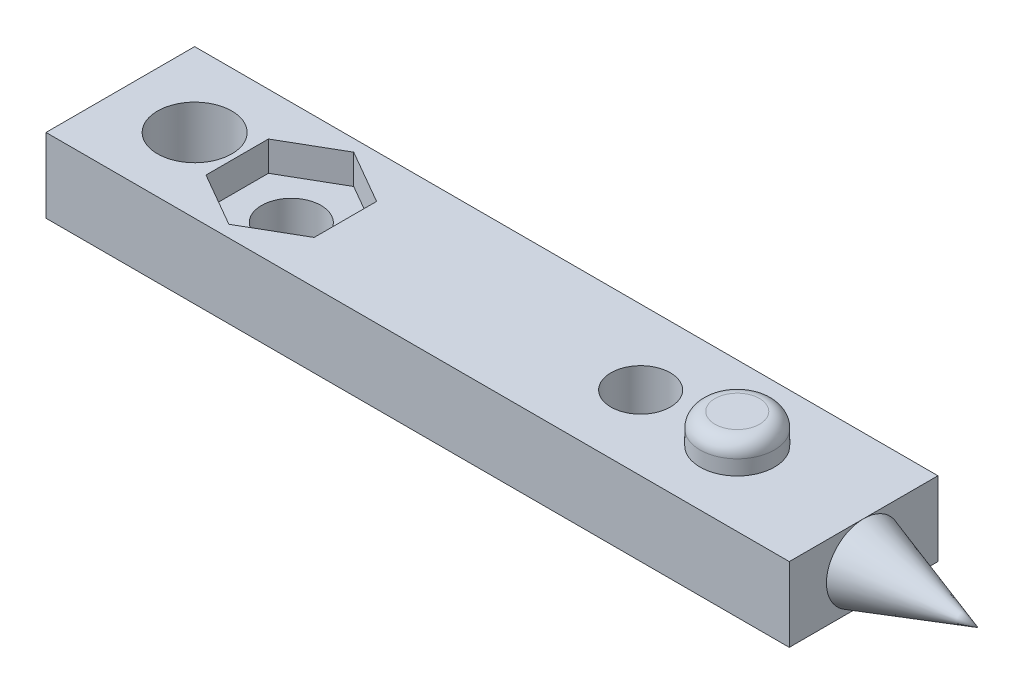
from build123d import *

# Parameters (mm, degrees)
SKETCH1_W           = 50
SKETCH1_H           = 10
BOSS_EXTRUDE1_DEPTH = 5
SKETCH2_R           = 2.5
SKETCH2_R_2         = 2
CUT_EXTRUDE1_DEPTH  = 5
SKETCH3_R           = 2
CUT_EXTRUDE2_DEPTH  = 5
CUT_EXTRUDE3_DEPTH  = 2
SKETCH5_R           = 2.5
BOSS_EXTRUDE2_DEPTH = 2
FILLET1_R           = 1


with BuildPart() as part:
    # Sketch1 → Boss-Extrude1 (new body)
    with BuildSketch(Plane(origin=(0, 0, 0), x_dir=(1, 0, 0), z_dir=(0, 1, 0))):
        with Locations((25, 5)):
            Rectangle(SKETCH1_W, SKETCH1_H)
    extrude(amount=BOSS_EXTRUDE1_DEPTH)

    # Sketch2 → Cut-Extrude1 (cut)
    with BuildSketch(Plane.XZ):
        with Locations(Location((5, -5, 0), (0, 0, 270))):
            Circle(SKETCH2_R)
        with Locations(Location((11.5, -5, 0), (0, 0, 270))):
            Circle(SKETCH2_R_2)
    extrude(amount=-CUT_EXTRUDE1_DEPTH, mode=Mode.SUBTRACT)

    # Sketch3 → Cut-Extrude2 (cut)
    with BuildSketch(Plane(origin=(0, 5, 0), x_dir=(1, 0, 0), z_dir=(0, 1, 0))):
        with Locations(Location((35, 5, 0), (0, 0, 270))):
            Circle(SKETCH3_R)
    extrude(amount=-CUT_EXTRUDE2_DEPTH, mode=Mode.SUBTRACT)

    # Sketch4 → Cut-Extrude3 (cut)
    with BuildSketch(Plane(origin=(0, 5, 0), x_dir=(1, 0, 0), z_dir=(0, 1, 0))):
        Polygon((11.5, 0.8), (15.137306696, 2.9), (15.137306696, 7.1), (11.5, 9.2), (7.862693304, 7.1), (7.862693304, 2.9), align=None)
    extrude(amount=-CUT_EXTRUDE3_DEPTH, mode=Mode.SUBTRACT)

    # Sketch5 → Boss-Extrude2 (add)
    with BuildSketch(Plane(origin=(0, 5, 0), x_dir=(1, 0, 0), z_dir=(0, 1, 0))):
        with Locations(Location((41.5, 5, 0), (0, 0, 90))):
            Circle(SKETCH5_R)
    extrude(amount=BOSS_EXTRUDE2_DEPTH)

    # Fillet1
    fillet1_edges = [part.edges().sort_by_distance(p)[0] for p in [
        (41.5, 7, -2.5),
    ]]
    fillet(fillet1_edges, radius=FILLET1_R)

    # Boss-Extrude3 cone 1 section (through the dimple's axis) → Boss-Extrude3 (revolve)
    with BuildSketch(Plane(origin=(50, 2.5, -5), x_dir=(0, 0, 1), z_dir=(0, 1, 0))):
        Polygon((0, 0), (2.5, 0), (0, 7.694208843), align=None)
    revolve(axis=Axis((50, 2.5, -5), (1, 0, 0)))


solid = part.part
